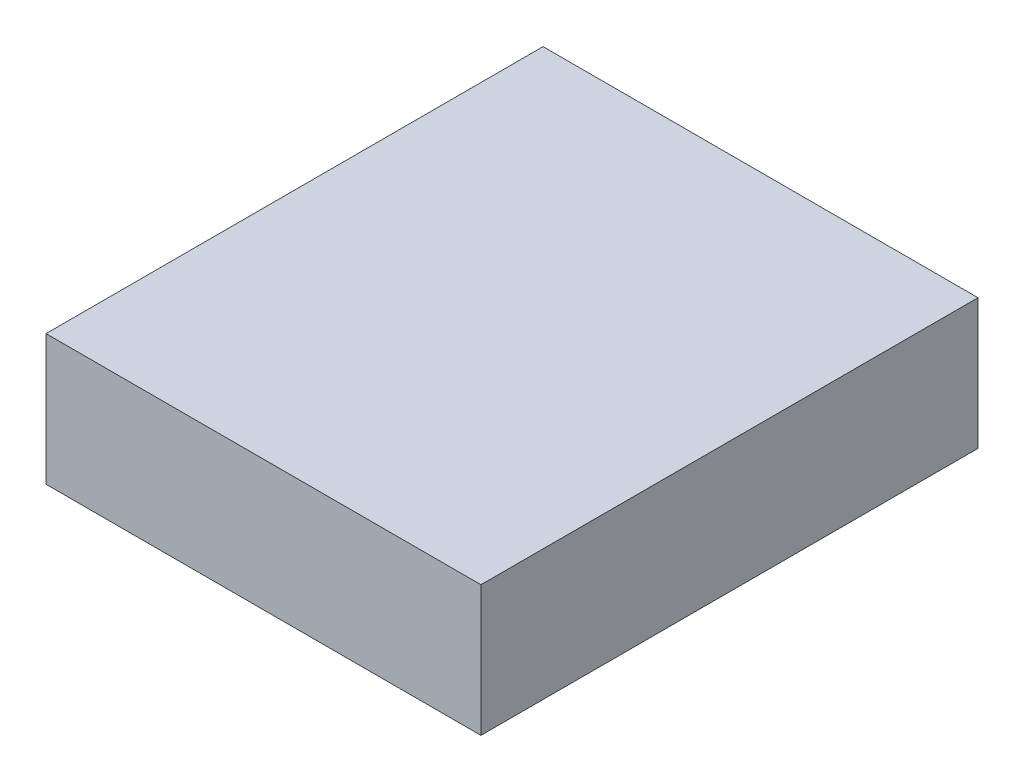
from build123d import *

# Parameters (mm, degrees)
SKETCH1_W           = 3.5
SKETCH1_H           = 4
BOSS_EXTRUDE1_DEPTH = 1.05


with BuildPart() as part:
    # Sketch1 → Boss-Extrude1 (new body)
    with BuildSketch(Plane(origin=(0, 0, 0), x_dir=(1, 0, 0), z_dir=(0, 1, 0))):
        Rectangle(SKETCH1_W, SKETCH1_H)
    extrude(amount=BOSS_EXTRUDE1_DEPTH)


solid = part.part
